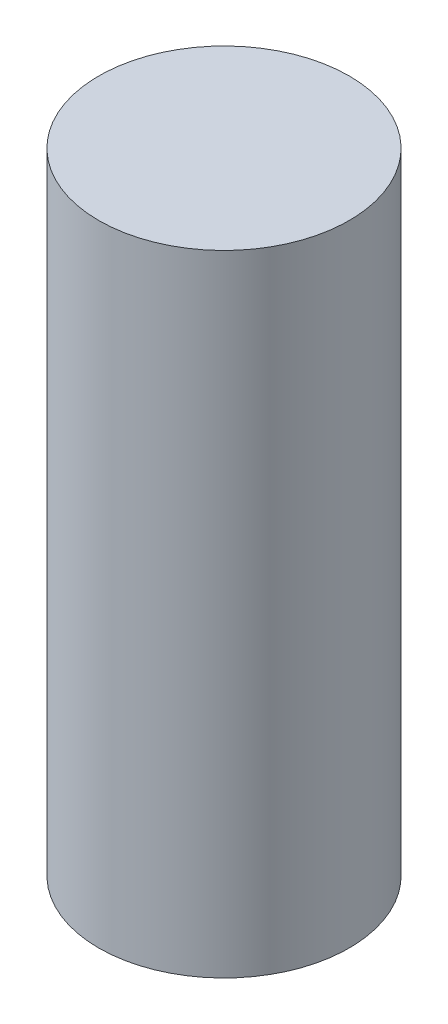
from build123d import *

# Parameters (mm, degrees)
SKETCH1_R           = 15.9
BOSS_EXTRUDE1_DEPTH = 80


with BuildPart() as part:
    # Sketch1 → Boss-Extrude1 (new body)
    with BuildSketch(Plane(origin=(0, 0, 0), x_dir=(1, 0, 0), z_dir=(0, 1, 0))):
        Circle(SKETCH1_R)
    extrude(amount=BOSS_EXTRUDE1_DEPTH)


solid = part.part
